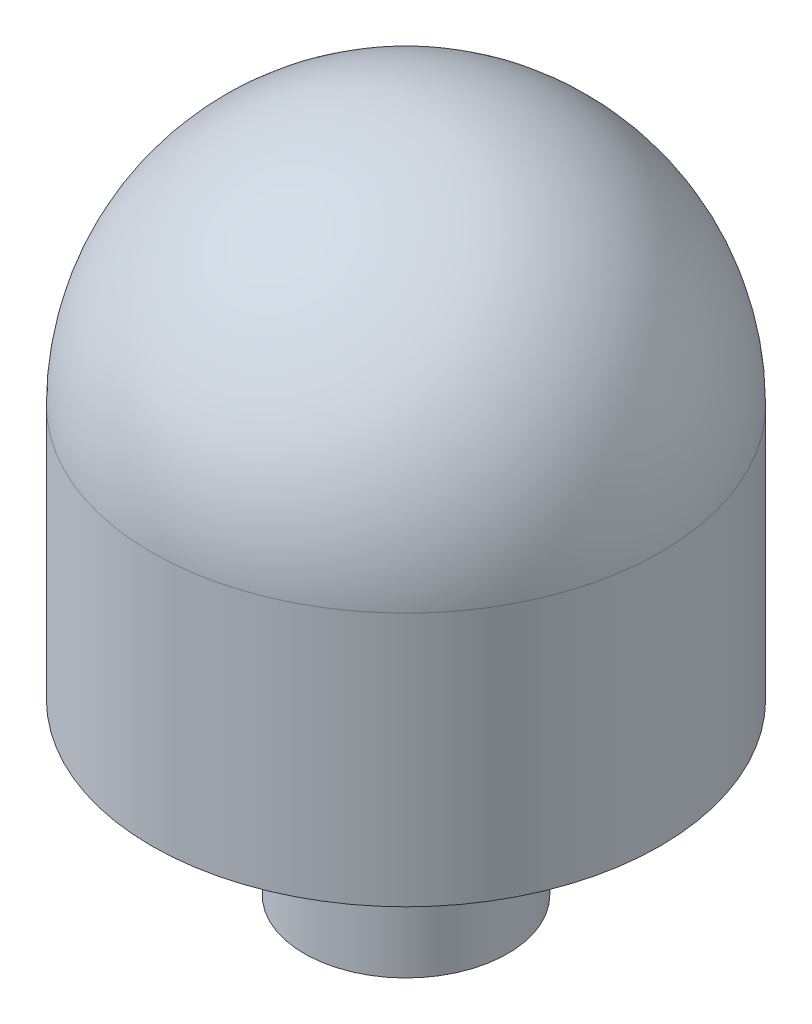
from build123d import *


with BuildPart() as part:
    # Croquis1 → Revolución1 (revolve)
    with BuildSketch(Plane.XY):
        with BuildLine():
            Line((0, 0), (-6, 0))
            Line((-6, 0), (-6, 10))
            Line((-6, 10), (-15, 10))
            Line((-15, 10), (-15, 25))
            ThreePointArc((-15, 25), (-10.606601718, 35.606601718), (0, 40))
            Line((0, 40), (0, 0))
        make_face()
    revolve(axis=Axis((0, 40, 0), (0, -1, 0)))


solid = part.part
